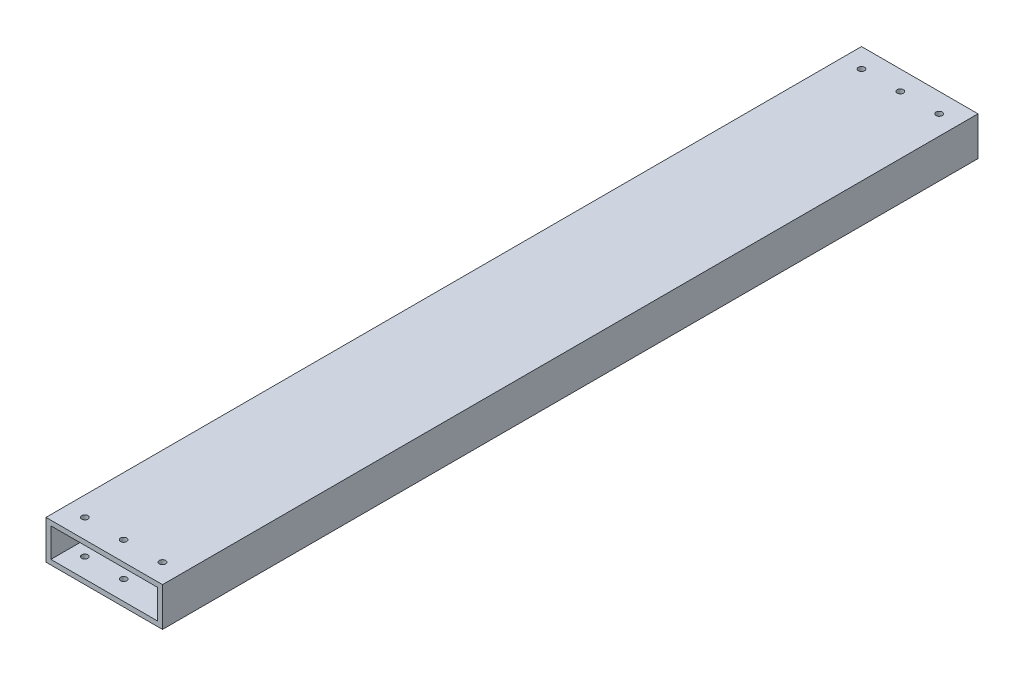
from build123d import *

# Parameters (mm, degrees)
SKETCH1_W           = 76.2
SKETCH1_H           = 25.4
SKETCH1_W_2         = 69.85
SKETCH1_H_2         = 19.05
EXTRUDE_THIN1_DEPTH = 266.7
SKETCH2_R           = 2.032
CUT_EXTRUDE1_DEPTH  = 26.4


with BuildPart() as part:
    # Sketch1 → Extrude-Thin1 (new body, symmetric)
    with BuildSketch(Plane.XY):
        Rectangle(SKETCH1_W, SKETCH1_H)
        Rectangle(SKETCH1_W_2, SKETCH1_H_2, mode=Mode.SUBTRACT)
    extrude(amount=EXTRUDE_THIN1_DEPTH, both=True)

    # Sketch2 → Cut-Extrude1 (cut, through all)
    with BuildSketch(Plane(origin=(0, 12.7, 0), x_dir=(1, 0, 0), z_dir=(0, 1, 0))):
        with Locations((25.4, 254)):
            Circle(SKETCH2_R)
        with Locations((0, 254)):
            Circle(SKETCH2_R)
        with Locations((25.4, -254)):
            Circle(SKETCH2_R)
        with Locations((0, -254)):
            Circle(SKETCH2_R)
        with Locations((-25.4, 254)):
            Circle(SKETCH2_R)
        with Locations((-25.4, -254)):
            Circle(SKETCH2_R)
    extrude(amount=-CUT_EXTRUDE1_DEPTH, mode=Mode.SUBTRACT)


solid = part.part
